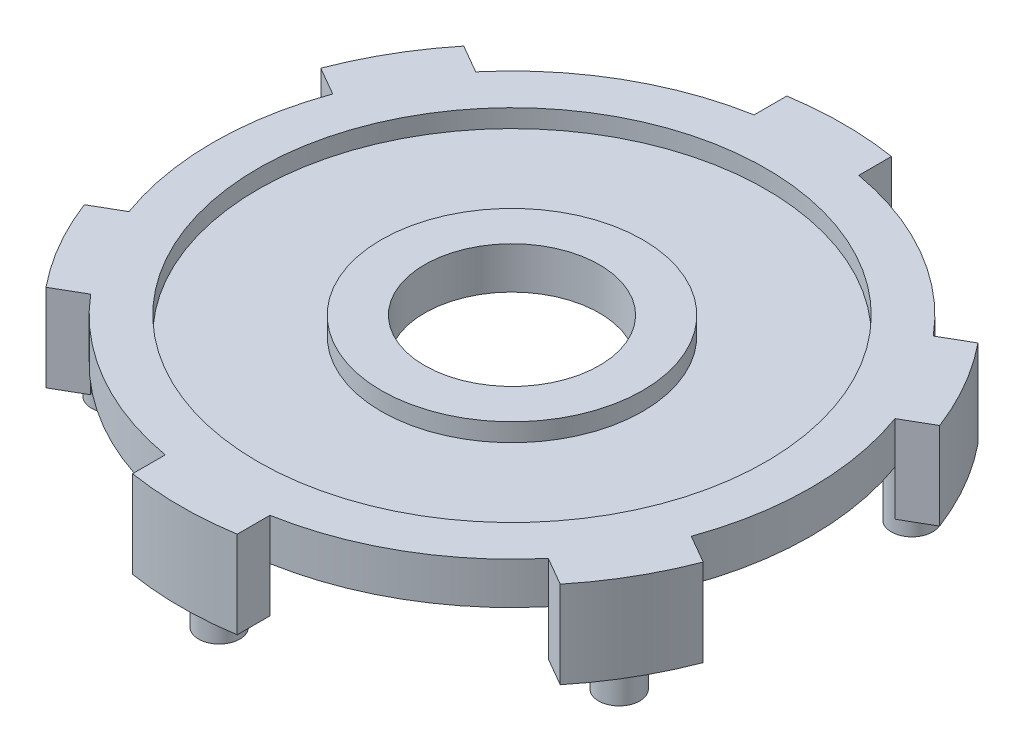
from build123d import *

# Parameters (mm, degrees)
SKETCH1_R           = 13.4239
BOSS_EXTRUDE1_DEPTH = 1.8796
BOSS_EXTRUDE2_DEPTH = 1.8796
SKETCH3_R           = 11.4046
CUT_EXTRUDE1_DEPTH  = 0.8128
SKETCH4_R           = 5.8674
BOSS_EXTRUDE3_DEPTH = 0.8128
SKETCH5_R           = 3.9243
CUT_EXTRUDE2_DEPTH  = 2.8796
SKETCH6_R           = 7.7216
BOSS_EXTRUDE4_DEPTH = 1.778
SKETCH7_R           = 6.5532
CUT_EXTRUDE3_DEPTH  = 1.778
BOSS_EXTRUDE5_DEPTH = 2.032
SKETCH9_R           = 0.9271
BOSS_EXTRUDE6_DEPTH = 3.683
CIRPATTERN1_COUNT   = 6


with BuildPart() as part:
    # Sketch1 → Boss-Extrude1 (new body)
    with BuildSketch(Plane(origin=(0, 0, 0), x_dir=(1, 0, 0), z_dir=(0, 1, 0))):
        Circle(SKETCH1_R)
    extrude(amount=BOSS_EXTRUDE1_DEPTH)

    # Sketch2 → Boss-Extrude2 (add)
    with BuildSketch(Plane(origin=(0, 1.8796, 0), x_dir=(1, 0, 0), z_dir=(0, 1, 0))):
        with BuildLine():
            Line((-13.892276606, 5.307740723), (-4.699, 0))
            Line((-4.699, 0), (-13.892276606, -5.307740723))
            ThreePointArc((-13.892276606, -5.307740723), (-12.879269997, -7.43585), (-11.542776606, -9.377194096))
            Line((-11.542776606, -9.377194096), (-2.3495, -4.069453372))
            Line((-2.3495, -4.069453372), (-2.3495, -14.684934819))
            ThreePointArc((-2.3495, -14.684934819), (0, -14.8717), (2.3495, -14.684934819))
            Line((2.3495, -14.684934819), (2.3495, -4.069453372))
            Line((2.3495, -4.069453372), (11.542776606, -9.377194096))
            ThreePointArc((11.542776606, -9.377194096), (12.879269997, -7.43585), (13.892276606, -5.307740723))
            Line((13.892276606, -5.307740723), (4.699, 0))
            Line((4.699, 0), (13.892276606, 5.307740723))
            ThreePointArc((13.892276606, 5.307740723), (12.879269997, 7.43585), (11.542776606, 9.377194096))
            Line((11.542776606, 9.377194096), (2.3495, 4.069453372))
            Line((2.3495, 4.069453372), (2.3495, 14.684934819))
            ThreePointArc((2.3495, 14.684934819), (0, 14.8717), (-2.3495, 14.684934819))
            Line((-2.3495, 14.684934819), (-2.3495, 4.069453372))
            Line((-2.3495, 4.069453372), (-11.542776606, 9.377194096))
            ThreePointArc((-11.542776606, 9.377194096), (-12.879269997, 7.43585), (-13.892276606, 5.307740723))
        make_face()
    extrude(amount=-BOSS_EXTRUDE2_DEPTH)

    # Sketch3 → Cut-Extrude1 (cut)
    with BuildSketch(Plane(origin=(0, 1.8796, 0), x_dir=(1, 0, 0), z_dir=(0, 1, 0))):
        Circle(SKETCH3_R)
    extrude(amount=-CUT_EXTRUDE1_DEPTH, mode=Mode.SUBTRACT)

    # Sketch4 → Boss-Extrude3 (add)
    with BuildSketch(Plane(origin=(0, 1.0668, 0), x_dir=(1, 0, 0), z_dir=(0, 1, 0))):
        Circle(SKETCH4_R)
    extrude(amount=BOSS_EXTRUDE3_DEPTH)

    # Sketch5 → Cut-Extrude2 (cut, through all)
    with BuildSketch(Plane(origin=(0, 1.8796, 0), x_dir=(1, 0, 0), z_dir=(0, 1, 0))):
        Circle(SKETCH5_R)
    extrude(amount=-CUT_EXTRUDE2_DEPTH, mode=Mode.SUBTRACT)

    # Sketch6 → Boss-Extrude4 (add)
    with BuildSketch(Plane.XZ):
        Circle(SKETCH6_R)
    extrude(amount=BOSS_EXTRUDE4_DEPTH)

    # Sketch7 → Cut-Extrude3 (cut)
    with BuildSketch(Plane.XZ.offset(1.778)):
        Circle(SKETCH7_R)
    extrude(amount=-CUT_EXTRUDE3_DEPTH, mode=Mode.SUBTRACT)

    # Sketch8 → Boss-Extrude5 (add)
    with BuildSketch(Plane.XZ):
        with BuildLine():
            Line((-2.3495, -13.216691756), (-2.3495, -14.684934819))
            ThreePointArc((-2.3495, -14.684934819), (0, -14.8717), (2.3495, -14.684934819))
            Line((2.3495, -14.684934819), (2.3495, -13.216691756))
            ThreePointArc((2.3495, -13.216691756), (0, -13.4239), (-2.3495, -13.216691756))
        make_face()
        with BuildLine():
            Line((10.271240814, -8.643072564), (11.542776606, -9.377194096))
            ThreePointArc((11.542776606, -9.377194096), (12.879269997, -7.43585), (13.892276606, -5.307740723))
            Line((13.892276606, -5.307740723), (12.620740814, -4.573619192))
            ThreePointArc((12.620740814, -4.573619192), (11.625438418, -6.71195), (10.271240814, -8.643072564))
        make_face()
        with BuildLine():
            Line((12.620740814, 4.573619192), (13.892276606, 5.307740723))
            ThreePointArc((13.892276606, 5.307740723), (12.879269997, 7.43585), (11.542776606, 9.377194096))
            Line((11.542776606, 9.377194096), (10.271240814, 8.643072564))
            ThreePointArc((10.271240814, 8.643072564), (11.625438418, 6.71195), (12.620740814, 4.573619192))
        make_face()
        with BuildLine():
            Line((2.3495, 13.216691756), (2.3495, 14.684934819))
            ThreePointArc((2.3495, 14.684934819), (0, 14.8717), (-2.3495, 14.684934819))
            Line((-2.3495, 14.684934819), (-2.3495, 13.216691756))
            ThreePointArc((-2.3495, 13.216691756), (0, 13.4239), (2.3495, 13.216691756))
        make_face()
        with BuildLine():
            Line((-10.271240814, 8.643072564), (-11.542776606, 9.377194096))
            ThreePointArc((-11.542776606, 9.377194096), (-12.879269997, 7.43585), (-13.892276606, 5.307740723))
            Line((-13.892276606, 5.307740723), (-12.620740814, 4.573619192))
            ThreePointArc((-12.620740814, 4.573619192), (-11.625438418, 6.71195), (-10.271240814, 8.643072564))
        make_face()
        with BuildLine():
            Line((-12.620740814, -4.573619192), (-13.892276606, -5.307740723))
            ThreePointArc((-13.892276606, -5.307740723), (-12.879269997, -7.43585), (-11.542776606, -9.377194096))
            Line((-11.542776606, -9.377194096), (-10.271240814, -8.643072564))
            ThreePointArc((-10.271240814, -8.643072564), (-11.625438418, -6.71195), (-12.620740814, -4.573619192))
        make_face()
    extrude(amount=BOSS_EXTRUDE5_DEPTH)

    # Sketch9 → Boss-Extrude6 (add)
    with BuildSketch(Plane.XZ):
        with Locations((0, 13.1445)):
            Circle(SKETCH9_R)
    boss_extrude6 = extrude(amount=BOSS_EXTRUDE6_DEPTH)

    # CirPattern1: Boss-Extrude6 ×6 about axis
    cirpattern1_axis = Axis((0, 0, 0), (0, 1, 0))
    for i in range(1, CIRPATTERN1_COUNT):
        add(boss_extrude6.rotate(cirpattern1_axis, i * 360 / CIRPATTERN1_COUNT))


solid = part.part
